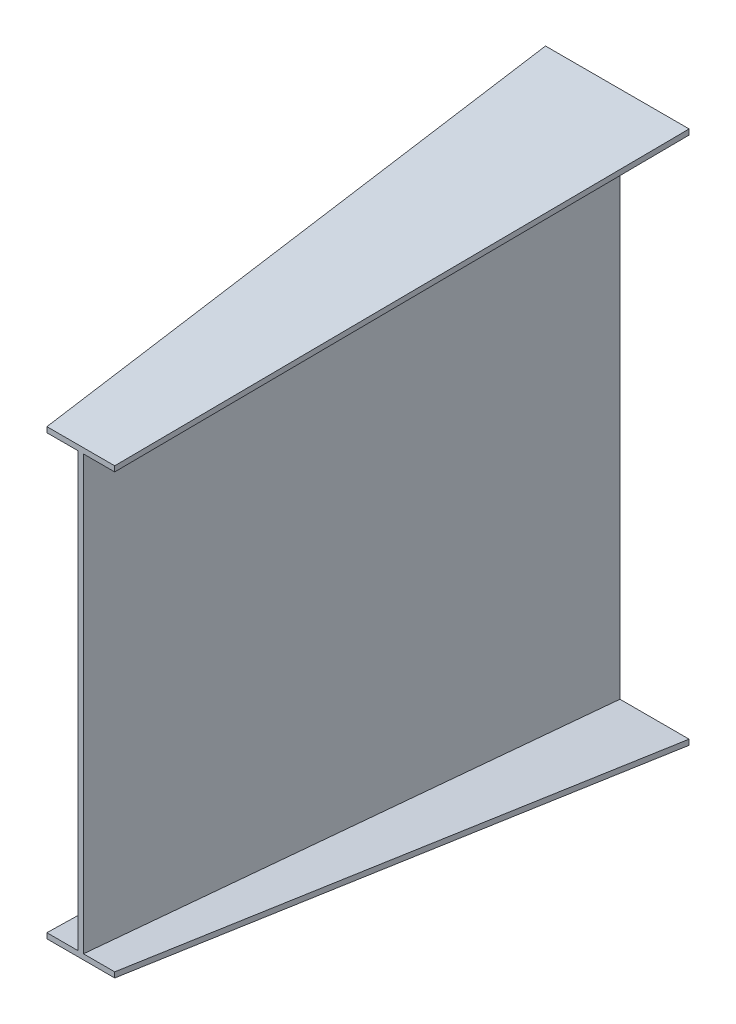
from build123d import *


with BuildPart() as part:
    # Sketch1 → Loft2 section 0
    with BuildSketch(Plane.XY):
        Polygon((-129.5, 0), (0, 0), (0, 980), (-129.5, 980), (-129.5, 990), (139.5, 990), (139.5, 980), (10, 980), (10, 0), (139.5, 0), (139.5, -10), (-129.5, -10), align=None)
    # Sketch3 → Loft2 section 1
    with BuildSketch(Plane.XY.offset(1000)):
        Polygon((-63.5, 895.5), (-5, 895.5), (-5, 84.5), (-63.5, 84.5), (-63.5, 74.5), (63.5, 74.5), (63.5, 84.5), (5, 84.5), (5, 895.5), (63.5, 895.5), (63.5, 905.5), (-63.5, 905.5), align=None)
    loft()


solid = part.part
